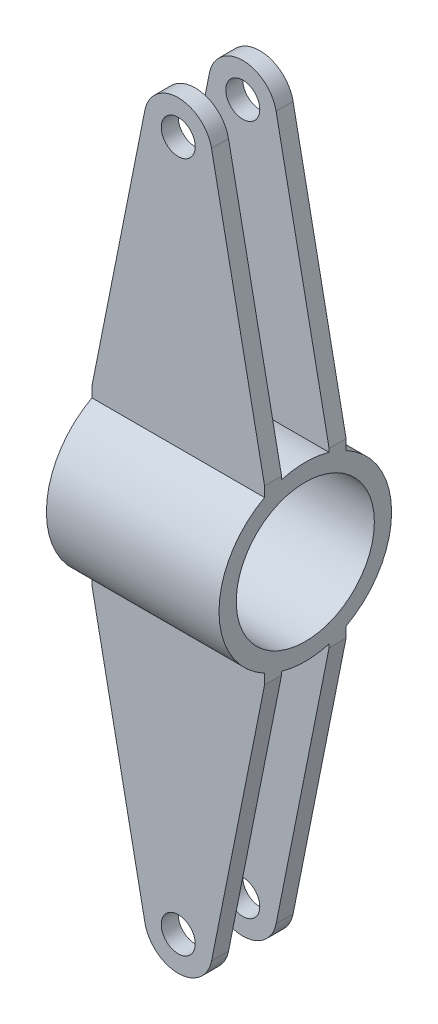
from build123d import *

# Parameters (mm, degrees)
SKETCH3_R             = 25.4
SKETCH3_R_2           = 20.32
BOSS_EXTRUDE1_DEPTH   = 25.4
BOSS_EXTRUDE3_START   = 7
SKETCH4_R             = 5
BOSS_EXTRUDE3_DEPTH   = 5
BOSS_EXTRUDE3_2_DEPTH = 5
BOSS_EXTRUDE4_START   = -7
SKETCH4_2_R           = 5
BOSS_EXTRUDE4_DEPTH   = 5
BOSS_EXTRUDE4_2_DEPTH = 5
BOSS_EXTRUDE5_DEPTH   = 25.4


with BuildPart() as part:
    # Sketch3 → Boss-Extrude1 (new, symmetric)
    with BuildSketch(Plane(origin=(0, 0, 0), x_dir=(0, 0, -1), z_dir=(1, 0, 0))):
        Circle(SKETCH3_R)
        Circle(SKETCH3_R_2, mode=Mode.SUBTRACT)
    extrude(amount=BOSS_EXTRUDE1_DEPTH, both=True)



with BuildPart() as body_2:
    # Sketch4 → Boss-Extrude3 (new body)
    with BuildSketch(Plane.XY.offset(BOSS_EXTRUDE3_START)):
        with BuildLine():
            Line((-25.4, 25.4), (-9.806723533, 103.556571886))
            ThreePointArc((-9.806723533, 103.556571886), (0, 111.6), (9.806723533, 103.556571886))
            Line((9.806723533, 103.556571886), (25.4, 25.4))
            Line((25.4, 25.4), (-25.4, 25.4))
        make_face()
        with Locations((0, 101.6)):
            Circle(SKETCH4_R, mode=Mode.SUBTRACT)
    extrude(amount=BOSS_EXTRUDE3_DEPTH)


with BuildPart() as body_3:
    # Sketch4 → Boss-Extrude3 2 (new body)
    with BuildSketch(Plane.XY.offset(BOSS_EXTRUDE3_START)):
        with BuildLine():
            Line((-25.4, -25.4), (-9.806723533, -103.556571886))
            ThreePointArc((-9.806723533, -103.556571886), (0, -111.6), (9.806723533, -103.556571886))
            Line((9.806723533, -103.556571886), (25.4, -25.4))
            Line((25.4, -25.4), (-25.4, -25.4))
        make_face()
        with Locations((0, -101.6)):
            Circle(SKETCH4_R, mode=Mode.SUBTRACT)
    extrude(amount=BOSS_EXTRUDE3_2_DEPTH)


with BuildPart() as body_4:
    # Sketch4_2 → Boss-Extrude4 (new body)
    with BuildSketch(Plane.XY.offset(BOSS_EXTRUDE4_START)):
        with BuildLine():
            Line((-25.4, 25.4), (-9.806723533, 103.556571886))
            ThreePointArc((-9.806723533, 103.556571886), (0, 111.6), (9.806723533, 103.556571886))
            Line((9.806723533, 103.556571886), (25.4, 25.4))
            Line((25.4, 25.4), (-25.4, 25.4))
        make_face()
        with Locations((0, 101.6)):
            Circle(SKETCH4_2_R, mode=Mode.SUBTRACT)
    extrude(amount=-BOSS_EXTRUDE4_DEPTH)


with BuildPart() as body_5:
    # Sketch4_2 → Boss-Extrude4 2 (new body)
    with BuildSketch(Plane.XY.offset(BOSS_EXTRUDE4_START)):
        with BuildLine():
            Line((-25.4, -25.4), (-9.806723533, -103.556571886))
            ThreePointArc((-9.806723533, -103.556571886), (0, -111.6), (9.806723533, -103.556571886))
            Line((9.806723533, -103.556571886), (25.4, -25.4))
            Line((25.4, -25.4), (-25.4, -25.4))
        make_face()
        with Locations((0, -101.6)):
            Circle(SKETCH4_2_R, mode=Mode.SUBTRACT)
    extrude(amount=-BOSS_EXTRUDE4_2_DEPTH)


with BuildPart() as part_1:
    add(part.part)

    add(body_2.part)  # Boss-Extrude5 merges body 2

    add(body_3.part)  # Boss-Extrude5 merges body 3

    add(body_4.part)  # Boss-Extrude5 merges body 4

    add(body_5.part)  # Boss-Extrude5 merges body 5
    # Sketch5 → Boss-Extrude5 (add, symmetric)
    with BuildSketch(Plane(origin=(0, 0, 0), x_dir=(0, 0, -1), z_dir=(1, 0, 0))):
        with BuildLine():
            Line((12, -25.4), (7, -25.4))
            Line((7, -25.4), (7, -24.416387939))
            ThreePointArc((7, -24.416387939), (9.554057075, -23.534655158), (12, -22.386603137))
            Line((12, -22.386603137), (12, -25.4))
        make_face()
        with BuildLine():
            Line((-12, -25.4), (-7, -25.4))
            Line((-7, -25.4), (-7, -24.416387939))
            ThreePointArc((-7, -24.416387939), (-9.554057075, -23.534655158), (-12, -22.386603137))
            Line((-12, -22.386603137), (-12, -25.4))
        make_face()
        with BuildLine():
            Line((12, 25.4), (7, 25.4))
            Line((7, 25.4), (7, 24.416387939))
            ThreePointArc((7, 24.416387939), (9.554057075, 23.534655158), (12, 22.386603137))
            Line((12, 22.386603137), (12, 25.4))
        make_face()
        with BuildLine():
            Line((-12, 25.4), (-7, 25.4))
            Line((-7, 25.4), (-7, 24.416387939))
            ThreePointArc((-7, 24.416387939), (-9.554057075, 23.534655158), (-12, 22.386603137))
            Line((-12, 22.386603137), (-12, 25.4))
        make_face()
    extrude(amount=BOSS_EXTRUDE5_DEPTH, both=True)


solid = part_1.part
